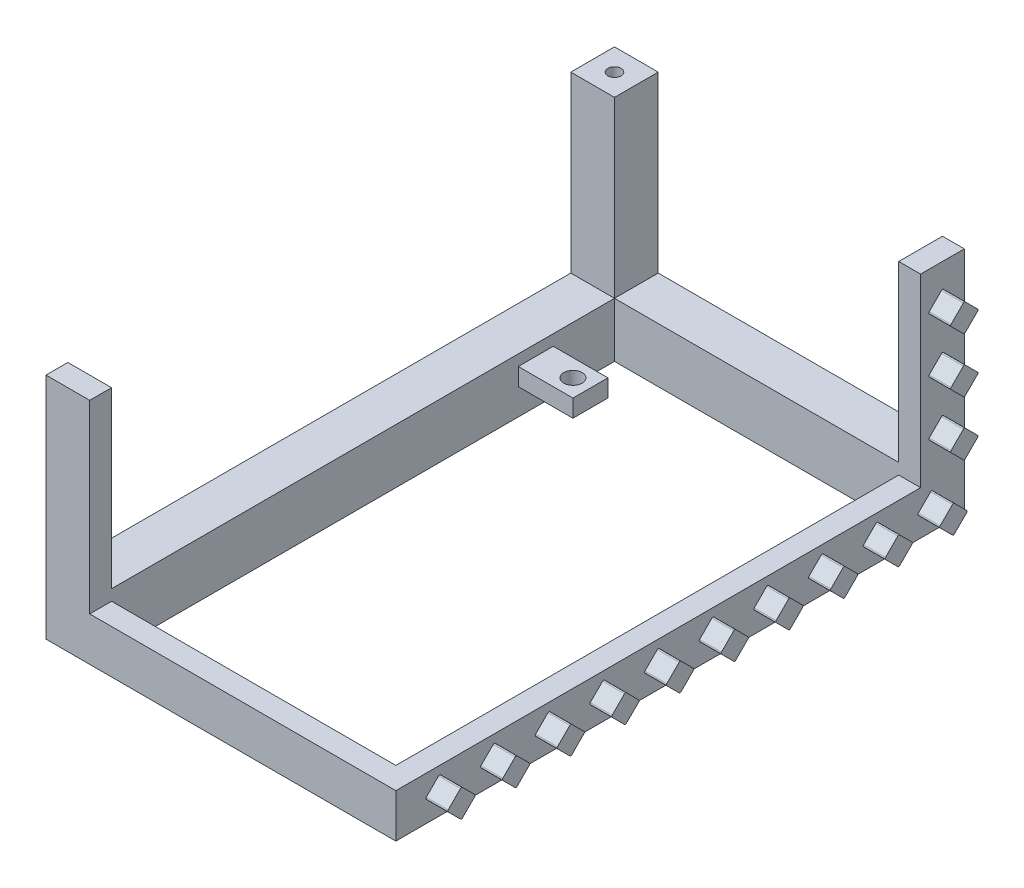
from build123d import *

# Parameters (mm, degrees)
SKETCH1_W            = 80
SKETCH1_H            = 130
BOSS_EXTRUDE1_DEPTH  = 10
BOSS_EXTRUDE10_DEPTH = 42.3
SKETCH13_W           = 115
SKETCH13_H           = 39.8
CUT_EXTRUDE3_DEPTH   = 11
SKETCH14_W           = 65
SKETCH14_H           = 39.8
CUT_EXTRUDE4_DEPTH   = 11
SKETCH15_R           = 1.5
CUT_EXTRUDE5_DEPTH   = 4
SKETCH21_R           = 2.1
CUT_EXTRUDE8_DEPTH   = 11
BOSS_EXTRUDE11_DEPTH = 5
CUT_EXTRUDE9_DEPTH   = 11
SKETCH24_R           = 1.5
CUT_EXTRUDE10_DEPTH  = 4
SKETCH25_W           = 12.5
SKETCH25_H           = 8
CUT_EXTRUDE11_DEPTH  = 6


with BuildPart() as part:
    # Sketch1 → Boss-Extrude1 (new body)
    with BuildSketch(Plane(origin=(0, 0, 0), x_dir=(1, 0, 0), z_dir=(0, 1, 0))):
        with Locations((-5, 5)):
            Rectangle(SKETCH1_W, SKETCH1_H)
    extrude(amount=BOSS_EXTRUDE1_DEPTH)

    # Sketch9 → Boss-Extrude10 (add)
    with BuildSketch(Plane(origin=(0, 10, 0), x_dir=(1, 0, 0), z_dir=(0, 1, 0))):
        Polygon((35, 70), (-45, 70), (-45, -60), (-35, -60), (-35, 60), (35, 60), align=None)
    extrude(amount=BOSS_EXTRUDE10_DEPTH)

    # Sketch13 → Cut-Extrude3 (cut, through all)
    with BuildSketch(Plane(origin=(-35, 0, 0), x_dir=(0, 0, -1), z_dir=(1, 0, 0))):
        with Locations((2.5, 32.4)):
            Rectangle(SKETCH13_W, SKETCH13_H)
    extrude(amount=-CUT_EXTRUDE3_DEPTH, mode=Mode.SUBTRACT)

    # Sketch14 → Cut-Extrude4 (cut, through all)
    with BuildSketch(Plane.XY.offset(-60)):
        with Locations((-2.5, 32.4)):
            Rectangle(SKETCH14_W, SKETCH14_H)
    extrude(amount=-CUT_EXTRUDE4_DEPTH, mode=Mode.SUBTRACT)

    # Sketch15 → Cut-Extrude5 (cut)
    with BuildSketch(Plane(origin=(0, 52.3, 0), x_dir=(1, 0, 0), z_dir=(0, 1, 0))):
        with Locations((-40, 65)):
            Circle(SKETCH15_R)
    extrude(amount=-CUT_EXTRUDE5_DEPTH, mode=Mode.SUBTRACT)

    # Sketch21 → Cut-Extrude8 (cut, through all)
    with BuildSketch(Plane(origin=(0, 10, 0), x_dir=(1, 0, 0), z_dir=(0, 1, 0))):
        with Locations((-26.5, 42)):
            Circle(SKETCH21_R)
    extrude(amount=-CUT_EXTRUDE8_DEPTH, mode=Mode.SUBTRACT)

    # Sketch22 → Boss-Extrude11 (add)
    with BuildSketch(Plane(origin=(35, 0, 0), x_dir=(0, 0, -1), z_dir=(1, 0, 0))):
        with BuildLine():
            Line((-0.212132034, 8.037867966), (-3.037867966, 5.212132034))
            ThreePointArc((-3.037867966, 5.212132034), (-3.125735931, 5), (-3.037867966, 4.787867966))
            Line((-3.037867966, 4.787867966), (-0.212132034, 1.962132034))
            ThreePointArc((-0.212132034, 1.962132034), (0, 1.874264069), (0.212132034, 1.962132034))
            Line((0.212132034, 1.962132034), (3.037867966, 4.787867966))
            ThreePointArc((3.037867966, 4.787867966), (3.125735931, 5), (3.037867966, 5.212132034))
            Line((3.037867966, 5.212132034), (0.212132034, 8.037867966))
            ThreePointArc((0.212132034, 8.037867966), (0, 8.125735931), (-0.212132034, 8.037867966))
        make_face()
        with BuildLine():
            Line((15.537867966, 5.212132034), (12.712132034, 8.037867966))
            ThreePointArc((12.712132034, 8.037867966), (12.5, 8.125735931), (12.287867966, 8.037867966))
            Line((12.287867966, 8.037867966), (9.462132034, 5.212132034))
            ThreePointArc((9.462132034, 5.212132034), (9.374264069, 5), (9.462132034, 4.787867966))
            Line((9.462132034, 4.787867966), (12.287867966, 1.962132034))
            ThreePointArc((12.287867966, 1.962132034), (12.5, 1.874264069), (12.712132034, 1.962132034))
            Line((12.712132034, 1.962132034), (15.537867966, 4.787867966))
            ThreePointArc((15.537867966, 4.787867966), (15.625735931, 5), (15.537867966, 5.212132034))
        make_face()
        with BuildLine():
            Line((28.037867966, 5.212132034), (25.212132034, 8.037867966))
            ThreePointArc((25.212132034, 8.037867966), (25, 8.125735931), (24.787867966, 8.037867966))
            Line((24.787867966, 8.037867966), (21.962132034, 5.212132034))
            ThreePointArc((21.962132034, 5.212132034), (21.874264069, 5), (21.962132034, 4.787867966))
            Line((21.962132034, 4.787867966), (24.787867966, 1.962132034))
            ThreePointArc((24.787867966, 1.962132034), (25, 1.874264069), (25.212132034, 1.962132034))
            Line((25.212132034, 1.962132034), (28.037867966, 4.787867966))
            ThreePointArc((28.037867966, 4.787867966), (28.125735931, 5), (28.037867966, 5.212132034))
        make_face()
        with BuildLine():
            Line((40.537867966, 5.212132034), (37.712132034, 8.037867966))
            ThreePointArc((37.712132034, 8.037867966), (37.5, 8.125735931), (37.287867966, 8.037867966))
            Line((37.287867966, 8.037867966), (34.462132034, 5.212132034))
            ThreePointArc((34.462132034, 5.212132034), (34.374264069, 5), (34.462132034, 4.787867966))
            Line((34.462132034, 4.787867966), (37.287867966, 1.962132034))
            ThreePointArc((37.287867966, 1.962132034), (37.5, 1.874264069), (37.712132034, 1.962132034))
            Line((37.712132034, 1.962132034), (40.537867966, 4.787867966))
            ThreePointArc((40.537867966, 4.787867966), (40.625735931, 5), (40.537867966, 5.212132034))
        make_face()
        with BuildLine():
            Line((53.037867966, 5.212132034), (50.212132034, 8.037867966))
            ThreePointArc((50.212132034, 8.037867966), (50, 8.125735931), (49.787867966, 8.037867966))
            Line((49.787867966, 8.037867966), (46.962132034, 5.212132034))
            ThreePointArc((46.962132034, 5.212132034), (46.874264069, 5), (46.962132034, 4.787867966))
            Line((46.962132034, 4.787867966), (49.787867966, 1.962132034))
            ThreePointArc((49.787867966, 1.962132034), (50, 1.874264069), (50.212132034, 1.962132034))
            Line((50.212132034, 1.962132034), (53.037867966, 4.787867966))
            ThreePointArc((53.037867966, 4.787867966), (53.125735931, 5), (53.037867966, 5.212132034))
        make_face()
        with BuildLine():
            Line((65.537867966, 5.212132034), (62.712132034, 8.037867966))
            ThreePointArc((62.712132034, 8.037867966), (62.5, 8.125735931), (62.287867966, 8.037867966))
            Line((62.287867966, 8.037867966), (59.462132034, 5.212132034))
            ThreePointArc((59.462132034, 5.212132034), (59.374264069, 5), (59.462132034, 4.787867966))
            Line((59.462132034, 4.787867966), (62.287867966, 1.962132034))
            ThreePointArc((62.287867966, 1.962132034), (62.5, 1.874264069), (62.712132034, 1.962132034))
            Line((62.712132034, 1.962132034), (65.537867966, 4.787867966))
            ThreePointArc((65.537867966, 4.787867966), (65.625735931, 5), (65.537867966, 5.212132034))
        make_face()
        with BuildLine():
            Line((-9.462132034, 5.212132034), (-12.287867966, 8.037867966))
            ThreePointArc((-12.287867966, 8.037867966), (-12.5, 8.125735931), (-12.712132034, 8.037867966))
            Line((-12.712132034, 8.037867966), (-15.537867966, 5.212132034))
            ThreePointArc((-15.537867966, 5.212132034), (-15.625735931, 5), (-15.537867966, 4.787867966))
            Line((-15.537867966, 4.787867966), (-12.712132034, 1.962132034))
            ThreePointArc((-12.712132034, 1.962132034), (-12.5, 1.874264069), (-12.287867966, 1.962132034))
            Line((-12.287867966, 1.962132034), (-9.462132034, 4.787867966))
            ThreePointArc((-9.462132034, 4.787867966), (-9.374264069, 5), (-9.462132034, 5.212132034))
        make_face()
        with BuildLine():
            Line((-21.962132034, 5.212132034), (-24.787867966, 8.037867966))
            ThreePointArc((-24.787867966, 8.037867966), (-25, 8.125735931), (-25.212132034, 8.037867966))
            Line((-25.212132034, 8.037867966), (-28.037867966, 5.212132034))
            ThreePointArc((-28.037867966, 5.212132034), (-28.125735931, 5), (-28.037867966, 4.787867966))
            Line((-28.037867966, 4.787867966), (-25.212132034, 1.962132034))
            ThreePointArc((-25.212132034, 1.962132034), (-25, 1.874264069), (-24.787867966, 1.962132034))
            Line((-24.787867966, 1.962132034), (-21.962132034, 4.787867966))
            ThreePointArc((-21.962132034, 4.787867966), (-21.874264069, 5), (-21.962132034, 5.212132034))
        make_face()
        with BuildLine():
            Line((-34.462132034, 5.212132034), (-37.287867966, 8.037867966))
            ThreePointArc((-37.287867966, 8.037867966), (-37.5, 8.125735931), (-37.712132034, 8.037867966))
            Line((-37.712132034, 8.037867966), (-40.537867966, 5.212132034))
            ThreePointArc((-40.537867966, 5.212132034), (-40.625735931, 5), (-40.537867966, 4.787867966))
            Line((-40.537867966, 4.787867966), (-37.712132034, 1.962132034))
            ThreePointArc((-37.712132034, 1.962132034), (-37.5, 1.874264069), (-37.287867966, 1.962132034))
            Line((-37.287867966, 1.962132034), (-34.462132034, 4.787867966))
            ThreePointArc((-34.462132034, 4.787867966), (-34.374264069, 5), (-34.462132034, 5.212132034))
        make_face()
        with BuildLine():
            Line((-46.962132034, 5.212132034), (-49.787867966, 8.037867966))
            ThreePointArc((-49.787867966, 8.037867966), (-50, 8.125735931), (-50.212132034, 8.037867966))
            Line((-50.212132034, 8.037867966), (-53.037867966, 5.212132034))
            ThreePointArc((-53.037867966, 5.212132034), (-53.125735931, 5), (-53.037867966, 4.787867966))
            Line((-53.037867966, 4.787867966), (-50.212132034, 1.962132034))
            ThreePointArc((-50.212132034, 1.962132034), (-50, 1.874264069), (-49.787867966, 1.962132034))
            Line((-49.787867966, 1.962132034), (-46.962132034, 4.787867966))
            ThreePointArc((-46.962132034, 4.787867966), (-46.874264069, 5), (-46.962132034, 5.212132034))
        make_face()
        with BuildLine():
            Line((61.962132034, 31.362132034), (64.787867966, 34.187867966))
            ThreePointArc((64.787867966, 34.187867966), (65, 34.275735931), (65.212132034, 34.187867966))
            Line((65.212132034, 34.187867966), (68.037867966, 31.362132034))
            ThreePointArc((68.037867966, 31.362132034), (68.125735931, 31.15), (68.037867966, 30.937867966))
            Line((68.037867966, 30.937867966), (65.212132034, 28.112132034))
            ThreePointArc((65.212132034, 28.112132034), (65, 28.024264069), (64.787867966, 28.112132034))
            Line((64.787867966, 28.112132034), (61.962132034, 30.937867966))
            ThreePointArc((61.962132034, 30.937867966), (61.874264069, 31.15), (61.962132034, 31.362132034))
        make_face()
        with BuildLine():
            Line((64.787867966, 40.612132034), (61.962132034, 43.437867966))
            ThreePointArc((61.962132034, 43.437867966), (61.874264069, 43.65), (61.962132034, 43.862132034))
            Line((61.962132034, 43.862132034), (64.787867966, 46.687867966))
            ThreePointArc((64.787867966, 46.687867966), (65, 46.775735931), (65.212132034, 46.687867966))
            Line((65.212132034, 46.687867966), (68.037867966, 43.862132034))
            ThreePointArc((68.037867966, 43.862132034), (68.125735931, 43.65), (68.037867966, 43.437867966))
            Line((68.037867966, 43.437867966), (65.212132034, 40.612132034))
            ThreePointArc((65.212132034, 40.612132034), (65, 40.524264069), (64.787867966, 40.612132034))
        make_face()
        with BuildLine():
            Line((64.787867966, 15.612132034), (61.962132034, 18.437867966))
            ThreePointArc((61.962132034, 18.437867966), (61.874264069, 18.65), (61.962132034, 18.862132034))
            Line((61.962132034, 18.862132034), (64.787867966, 21.687867966))
            ThreePointArc((64.787867966, 21.687867966), (65, 21.775735931), (65.212132034, 21.687867966))
            Line((65.212132034, 21.687867966), (68.037867966, 18.862132034))
            ThreePointArc((68.037867966, 18.862132034), (68.125735931, 18.65), (68.037867966, 18.437867966))
            Line((68.037867966, 18.437867966), (65.212132034, 15.612132034))
            ThreePointArc((65.212132034, 15.612132034), (65, 15.524264069), (64.787867966, 15.612132034))
        make_face()
    extrude(amount=BOSS_EXTRUDE11_DEPTH)

    # Sketch23 → Cut-Extrude9 (cut, through all)
    with BuildSketch(Plane(origin=(0, 10, 0), x_dir=(1, 0, 0), z_dir=(0, 1, 0))):
        Polygon((30, -55), (-35, -55), (-35, 38), (-22.5, 38), (-22.5, 46), (-35, 46), (-35, 60), (30, 60), align=None)
    extrude(amount=-CUT_EXTRUDE9_DEPTH, mode=Mode.SUBTRACT)

    # Sketch24 → Cut-Extrude10 (cut)
    with BuildSketch(Plane.XZ):
        with Locations((-40, -65)):
            Circle(SKETCH24_R)
    extrude(amount=-CUT_EXTRUDE10_DEPTH, mode=Mode.SUBTRACT)

    # Sketch25 → Cut-Extrude11 (cut)
    with BuildSketch(Plane.XZ):
        with Locations((-28.75, -42)):
            Rectangle(SKETCH25_W, SKETCH25_H)
    extrude(amount=-CUT_EXTRUDE11_DEPTH, mode=Mode.SUBTRACT)


solid = part.part
